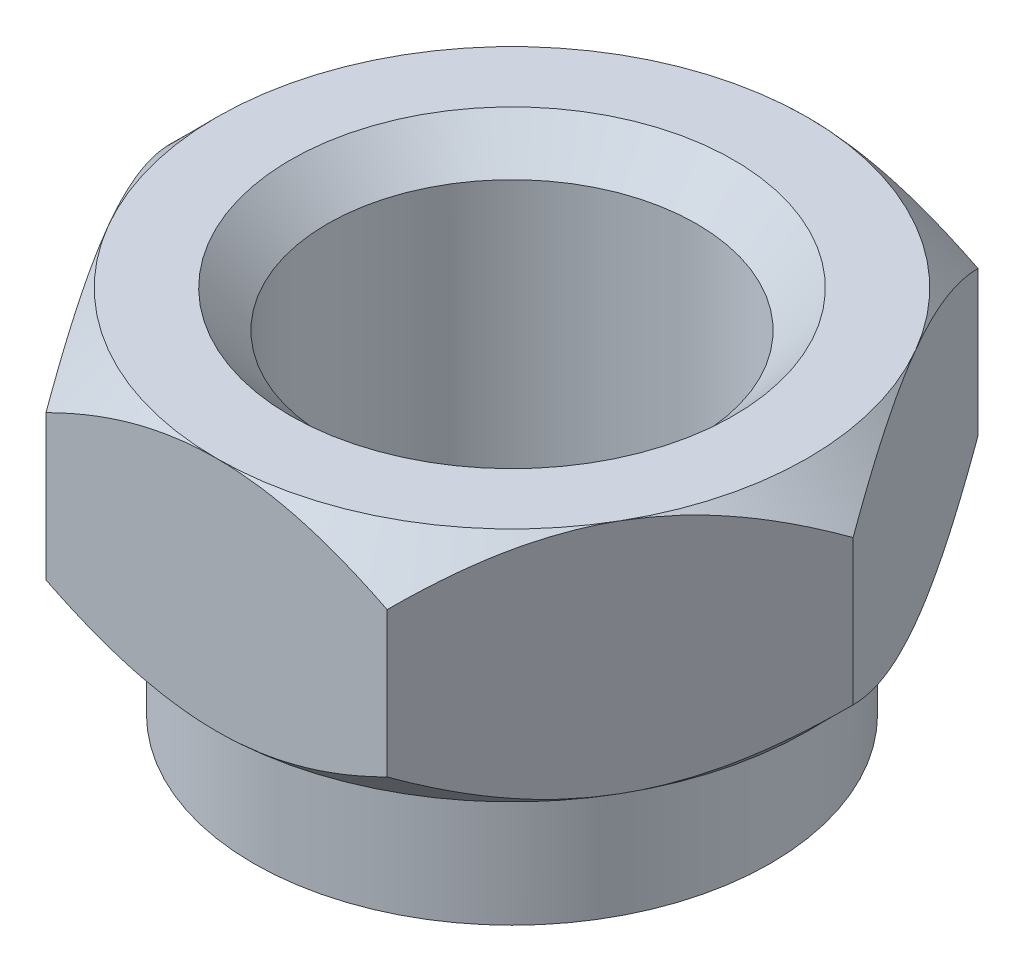
from build123d import *

# Parameters (mm, degrees)
SZKIC1_R                    = 2.5
DODANIE_WYCI_GNI_CIE1_DEPTH = 3.2
SZKIC2_OUTSIDE_W            = 22.164
SZKIC2_OUTSIDE_H            = 20.926
SZKIC2_OUTSIDE_R            = 4
WYTNIJ_WYCI_GNI_CIE29_DEPTH = 4.2
WYTNIJ_WYCI_GNI_CIE29_TAPER = 45
SZKIC4_R                    = 3.5
SZKIC4_R_2                  = 2.5
DODANIE_WYCI_GNI_CIE2_DEPTH = 1.8
SZKIC5_OUTSIDE_W            = 33.878
SZKIC5_OUTSIDE_H            = 32.64
SZKIC5_OUTSIDE_R            = 4
WYTNIJ_WYCI_GNI_CIE30_DEPTH = 10
WYTNIJ_WYCI_GNI_CIE30_TAPER = 45
ZAOKR_GLENIE1_R             = 0.1
SFAZOWANIE1_SIZE            = 0.5


with BuildPart() as part:
    # Szkic1 → Dodanie-wyciągnięcie1 (new body)
    with BuildSketch(Plane(origin=(0, 0, 0), x_dir=(1, 0, 0), z_dir=(0, 1, 0))):
        Polygon((4.618802154, 0), (2.309401077, 4), (-2.309401077, 4), (-4.618802154, 0), (-2.309401077, -4), (2.309401077, -4), align=None)
        Circle(SZKIC1_R, mode=Mode.SUBTRACT)
    extrude(amount=DODANIE_WYCI_GNI_CIE1_DEPTH)

    # Szkic2 outside → Wytnij-wyciągnięcie29 (cut, through all)
    with BuildSketch(Plane(origin=(0, 3.2, 0), x_dir=(1, 0, 0), z_dir=(0, 1, 0))):
        Rectangle(SZKIC2_OUTSIDE_W, SZKIC2_OUTSIDE_H)
        Circle(SZKIC2_OUTSIDE_R, mode=Mode.SUBTRACT)
    extrude(amount=-WYTNIJ_WYCI_GNI_CIE29_DEPTH, taper=WYTNIJ_WYCI_GNI_CIE29_TAPER, mode=Mode.SUBTRACT)

    # Szkic4 → Dodanie-wyciągnięcie2 (add)
    with BuildSketch(Plane(origin=(0, 0, 0), x_dir=(-1, 0, 0), z_dir=(0, -1, 0))):
        Circle(SZKIC4_R)
        Circle(SZKIC4_R_2, mode=Mode.SUBTRACT)
    extrude(amount=DODANIE_WYCI_GNI_CIE2_DEPTH)

    # Szkic5 outside → Wytnij-wyciągnięcie30 (cut)
    with BuildSketch(Plane(origin=(0, 0, 0), x_dir=(-1, 0, 0), z_dir=(0, -1, 0))):
        Rectangle(SZKIC5_OUTSIDE_W, SZKIC5_OUTSIDE_H)
        Circle(SZKIC5_OUTSIDE_R, mode=Mode.SUBTRACT)
    extrude(amount=-WYTNIJ_WYCI_GNI_CIE30_DEPTH, taper=WYTNIJ_WYCI_GNI_CIE30_TAPER, mode=Mode.SUBTRACT)

    # Zaokrąglenie1
    zaokr_glenie1_edges = [part.edges().sort_by_distance(p)[0] for p in [
        (3.5, 0, 0),
    ]]
    fillet(zaokr_glenie1_edges, radius=ZAOKR_GLENIE1_R)

    # Sfazowanie1
    sfazowanie1_edges = [part.edges().sort_by_distance(p)[0] for p in [
        (-2.5, 3.2, 0),
        (2.5, -1.8, 0),
    ]]
    chamfer(sfazowanie1_edges, length=SFAZOWANIE1_SIZE)


solid = part.part
